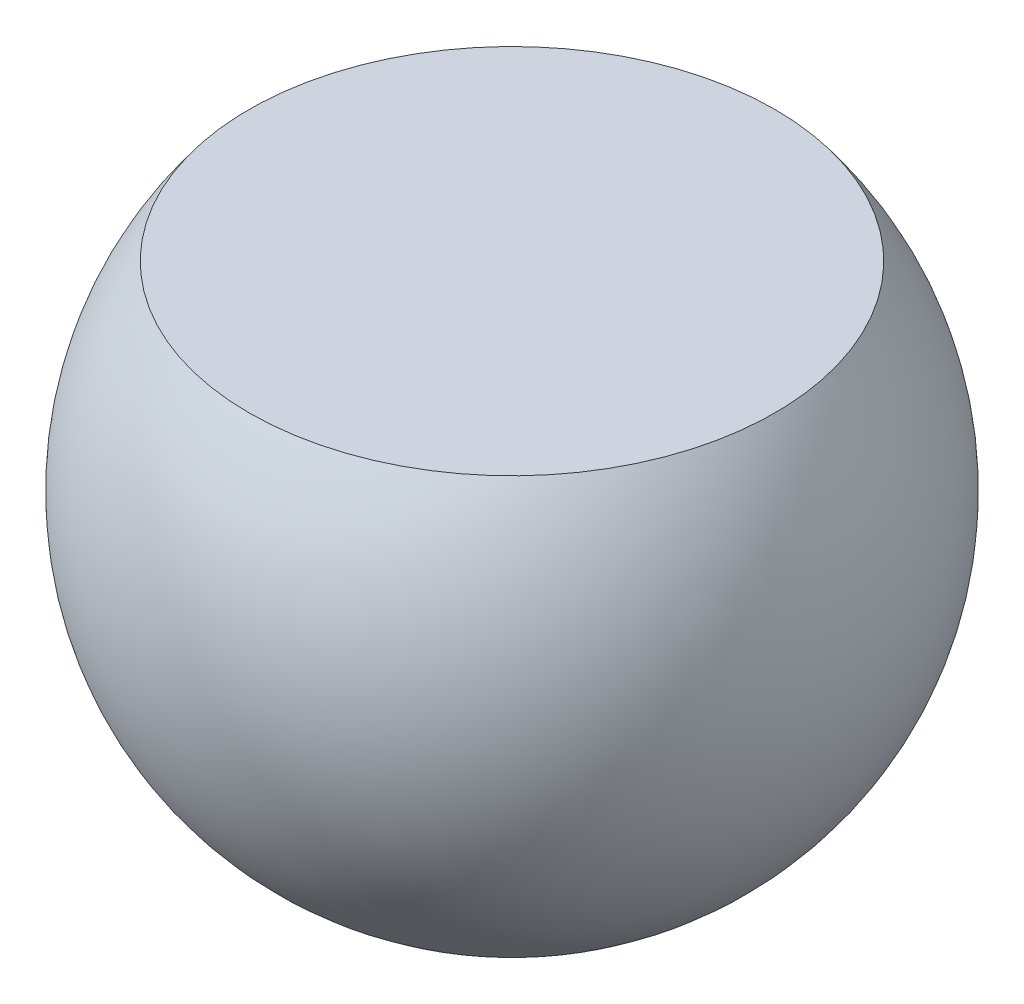
from build123d import *

# Parameters (mm, degrees)
SKETCH3_W          = 8.432018594
SKETCH3_H          = 8.257563036
CUT_EXTRUDE1_DEPTH = 2.54


with BuildPart() as part:
    # Sketch1 → Revolve2 (revolve)
    with BuildSketch(Plane(origin=(0, 0, 0), x_dir=(1, 0, 0), z_dir=(0, 1, 0))):
        with BuildLine():
            Line((0, 1.682500064), (0, -1.682500064))
            ThreePointArc((0, -1.682500064), (-1.682500064, 0), (0, 1.682500064))
        make_face()
    revolve(axis=Axis((0, 0, -1.682500064), (0, 0, 1)))

    # Sketch3 → Cut-Extrude1 (cut)
    with BuildSketch(Plane(origin=(0, 1.016, 0), x_dir=(1, 0, 0), z_dir=(0, 1, 0))):
        Rectangle(SKETCH3_W, SKETCH3_H)
    extrude(amount=CUT_EXTRUDE1_DEPTH, mode=Mode.SUBTRACT)


solid = part.part
